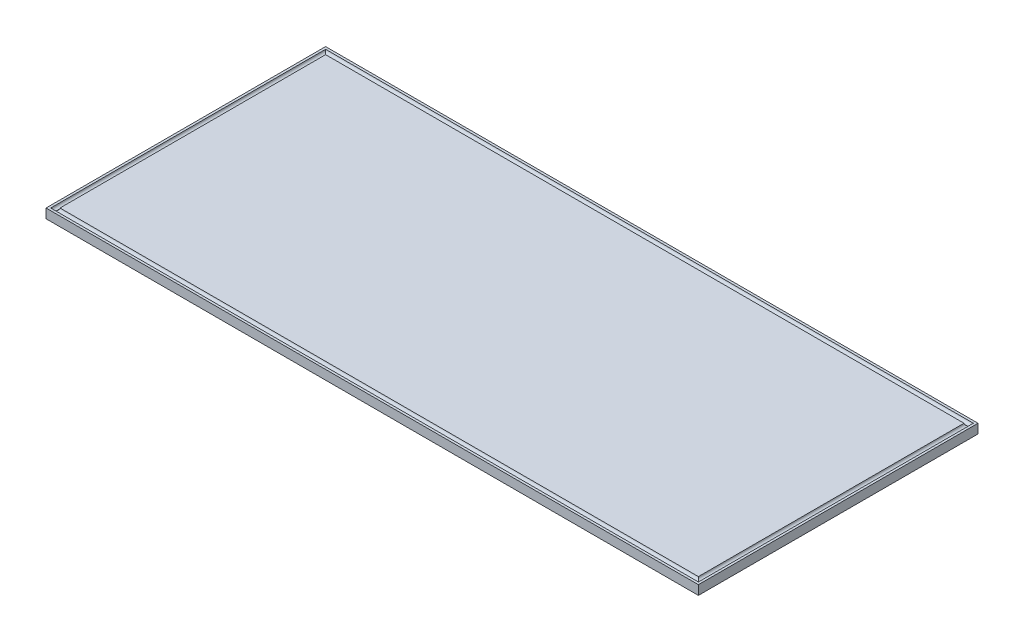
from build123d import *

# Parameters (mm, degrees)
SKETCH1_W            = 140
SKETCH1_H            = 60
BOSS_EXTRUDE1_DEPTH  = 2
CUT_SWEEP1_PROFILE_R = 0.5


with BuildPart() as part:
    # Sketch1 → Boss-Extrude1 (new body)
    with BuildSketch(Plane(origin=(0, 0, 0), x_dir=(1, 0, 0), z_dir=(0, 1, 0))):
        with Locations((-70, -30)):
            Rectangle(SKETCH1_W, SKETCH1_H)
    extrude(amount=BOSS_EXTRUDE1_DEPTH)

    # Cut-Sweep1: sweep along a path in Sketch2
    with BuildLine(Plane(origin=(0, 2, 0), x_dir=(1, 0, 0), z_dir=(0, 1, 0))) as cut_sweep1_path:
        Line((-1, -59), (-1, -1))
        Line((-1, -1), (-139, -1))
        Line((-139, -1), (-139, -59))
        Line((-139, -59), (-1, -59))
    # Cut-Sweep1 profile (on start of the path) → Cut-Sweep1 (sweep, cut)
    with BuildSketch(Plane(origin=(-1, 2, 59), x_dir=(-1, 0, 0), z_dir=(0, 0, -1))):
        Circle(CUT_SWEEP1_PROFILE_R)
    sweep(path=cut_sweep1_path.line, transition=Transition.RIGHT, mode=Mode.SUBTRACT)


solid = part.part
